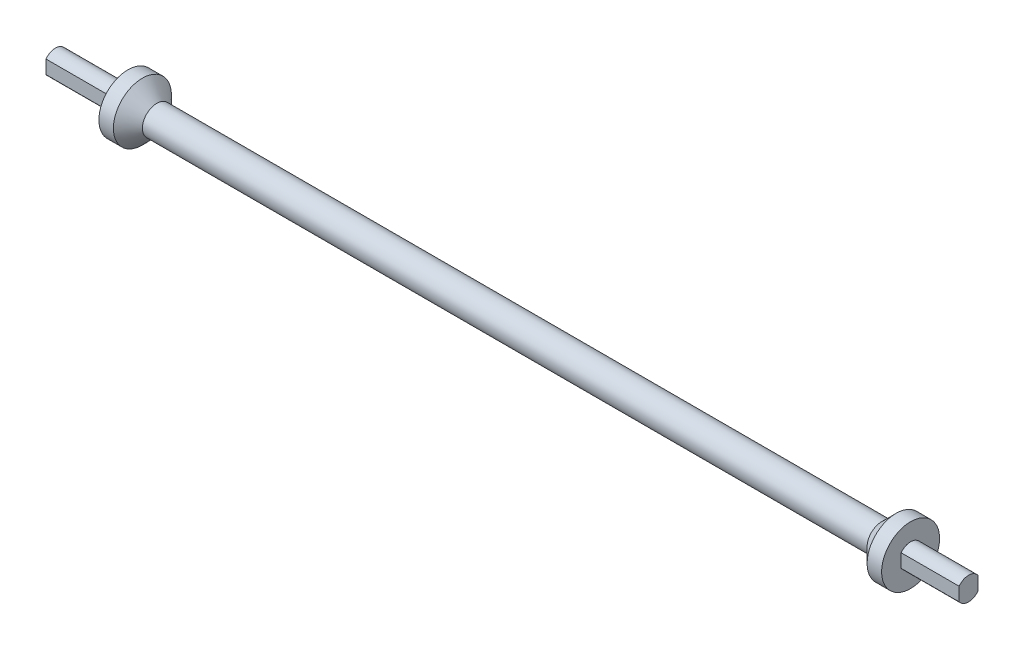
from build123d import *

# Parameters (mm, degrees)
SKETCH3_R               = 4
BOSS_EXTRUDE3_DEPTH     = 5
SKETCH2_W               = 25
SKETCH2_H               = 0.75
SKETCH2_W_2             = 20
CUT_EXTRUDE1_DEPTH      = 11
CUT_EXTRUDE1_DEPTH_BACK = 11


with BuildPart() as part:
    # Sketch1 → Revolve3 (revolve)
    with BuildSketch(Plane.XY):
        Polygon((-125, 5), (125, 5), (130, 10), (135, 10), (135, 4), (155, 4), (155, 0), (-155, 0), (-155, 4), (-135, 4), (-135, 10), (-130, 10), align=None)
    revolve(axis=Axis((-25.367414289, 0, 0), (1, 0, 0)))

    # Sketch3 → Boss-Extrude3 (add)
    with BuildSketch(Plane.ZY.offset(155)):
        Circle(SKETCH3_R)
    extrude(amount=BOSS_EXTRUDE3_DEPTH)

    # Sketch2 → Cut-Extrude1 (cut, two sides)
    with BuildSketch(Plane(origin=(0, 0, 0), x_dir=(1, 0, 0), z_dir=(0, 1, 0))) as cut_extrude1_sk:
        with Locations((-147.5, 3.625)):
            Rectangle(SKETCH2_W, SKETCH2_H)
        with Locations((145, -3.625)):
            Rectangle(SKETCH2_W_2, SKETCH2_H)
        with Locations((145, 3.625)):
            Rectangle(SKETCH2_W_2, SKETCH2_H)
        with Locations((-147.5, -3.625)):
            Rectangle(SKETCH2_W, SKETCH2_H)
    extrude(amount=CUT_EXTRUDE1_DEPTH, mode=Mode.SUBTRACT)
    extrude(cut_extrude1_sk.sketch, amount=-CUT_EXTRUDE1_DEPTH_BACK, mode=Mode.SUBTRACT)


solid = part.part
